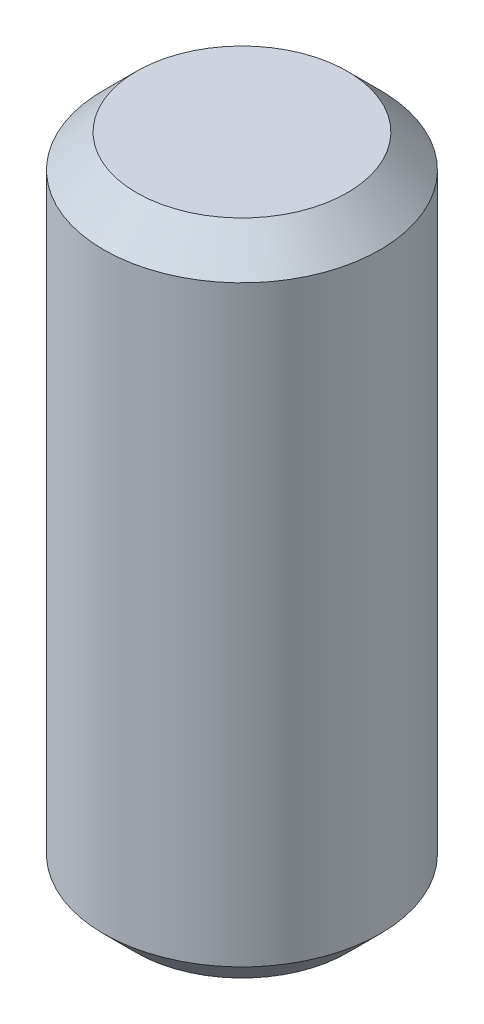
from build123d import *

# Parameters (mm, degrees)
SZKIC1_R                    = 42
DODANIE_WYCI_GNI_CIE1_DEPTH = 200
SFAZOWANIE1_SIZE            = 10
SKORUPA1_T                  = -0.2
SZKIC8_R                    = 32
DODANIE_WYCI_GNI_CIE4_DEPTH = 0.2


with BuildPart() as part:
    # Szkic1 → Dodanie-wyciągnięcie1 (new body)
    with BuildSketch(Plane(origin=(0, 0, 0), x_dir=(1, 0, 0), z_dir=(0, 1, 0))):
        with Locations(Location((0, 0, 0), (0, 0, 270))):
            Circle(SZKIC1_R)
    extrude(amount=DODANIE_WYCI_GNI_CIE1_DEPTH)

    # Sfazowanie1
    sfazowanie1_edges = [part.edges().sort_by_distance(p)[0] for p in [
        (0, 0, -42),
        (0, 200, -42),
    ]]
    chamfer(sfazowanie1_edges, length=SFAZOWANIE1_SIZE)

    # Skorupa1
    skorupa1_openings = [part.faces().sort_by_distance(p)[0] for p in [
        (0, 200, 0),
    ]]
    offset(amount=SKORUPA1_T, openings=skorupa1_openings, kind=Kind.INTERSECTION)

    # Szkic8 → Dodanie-wyciągnięcie4 (add)
    with BuildSketch(Plane(origin=(0, 200, 0), x_dir=(1, 0, 0), z_dir=(0, 1, 0))):
        Circle(SZKIC8_R)
    extrude(amount=-DODANIE_WYCI_GNI_CIE4_DEPTH)


solid = part.part
